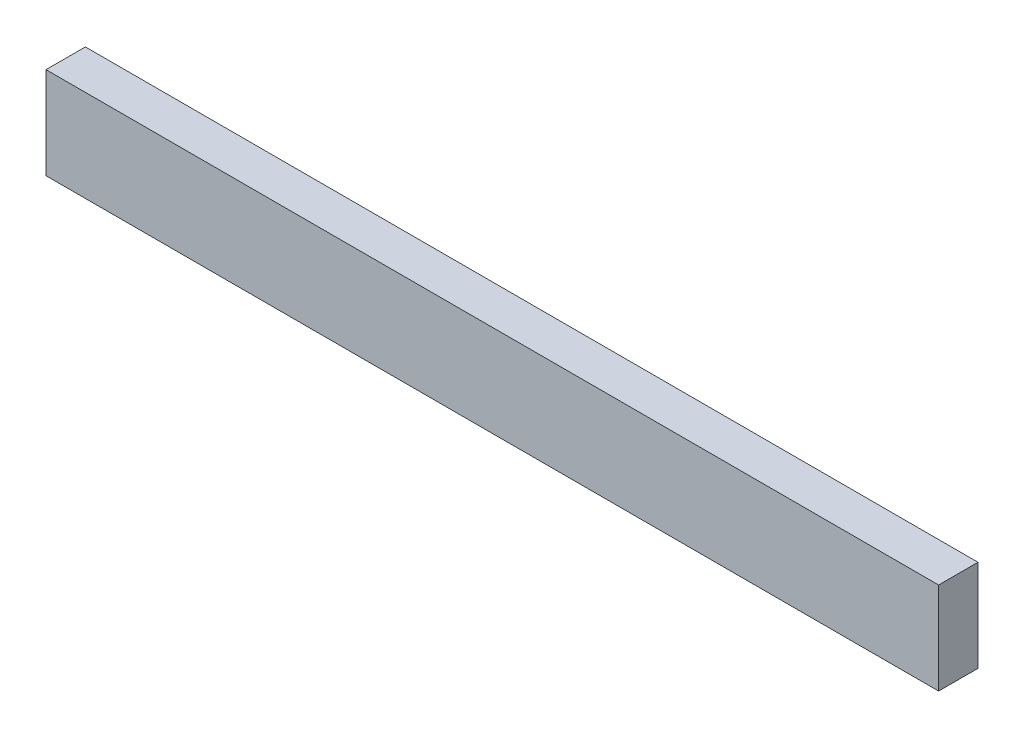
from build123d import *

# Parameters (mm, degrees)
SKETCH3_W                = 38.1
SKETCH3_H                = 88.9
BOSS_EXTRUDE1_DEPTH      = 431.8
BOSS_EXTRUDE1_DEPTH_BACK = 431.8


with BuildPart() as part:
    # Sketch3 → Boss-Extrude1 (new body, two sides)
    with BuildSketch(Plane(origin=(0, 0, 0), x_dir=(0, 0, -1), z_dir=(1, 0, 0))) as boss_extrude1_sk:
        Rectangle(SKETCH3_W, SKETCH3_H)
    extrude(amount=BOSS_EXTRUDE1_DEPTH)
    extrude(boss_extrude1_sk.sketch, amount=-BOSS_EXTRUDE1_DEPTH_BACK)


solid = part.part
